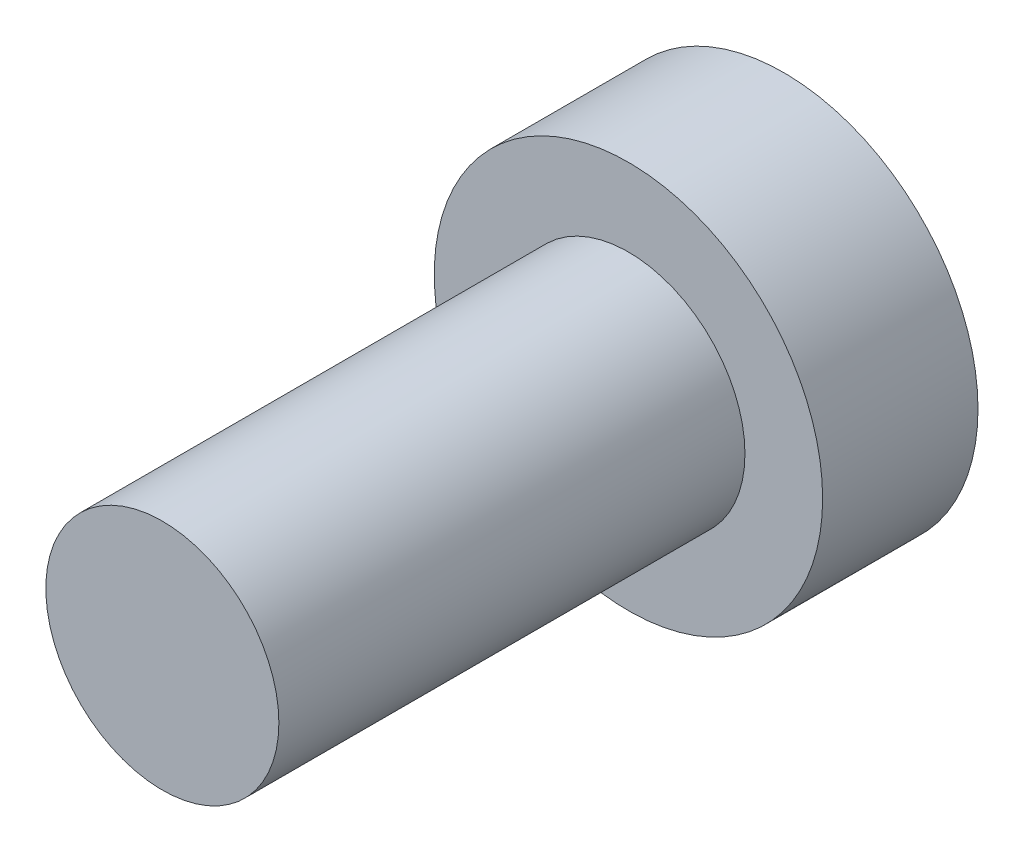
from build123d import *

# Parameters (mm, degrees)
SKETCH1_R           = 2.5
BOSS_EXTRUDE1_DEPTH = 2
SKETCH2_R           = 1.5
BOSS_EXTRUDE2_DEPTH = 6


with BuildPart() as part:
    # Sketch1 → Boss-Extrude1 (new body)
    with BuildSketch(Plane.XY):
        Circle(SKETCH1_R)
    extrude(amount=BOSS_EXTRUDE1_DEPTH)

    # Sketch2 → Boss-Extrude2 (add)
    with BuildSketch(Plane.XY.offset(2)):
        Circle(SKETCH2_R)
    extrude(amount=BOSS_EXTRUDE2_DEPTH)


solid = part.part
